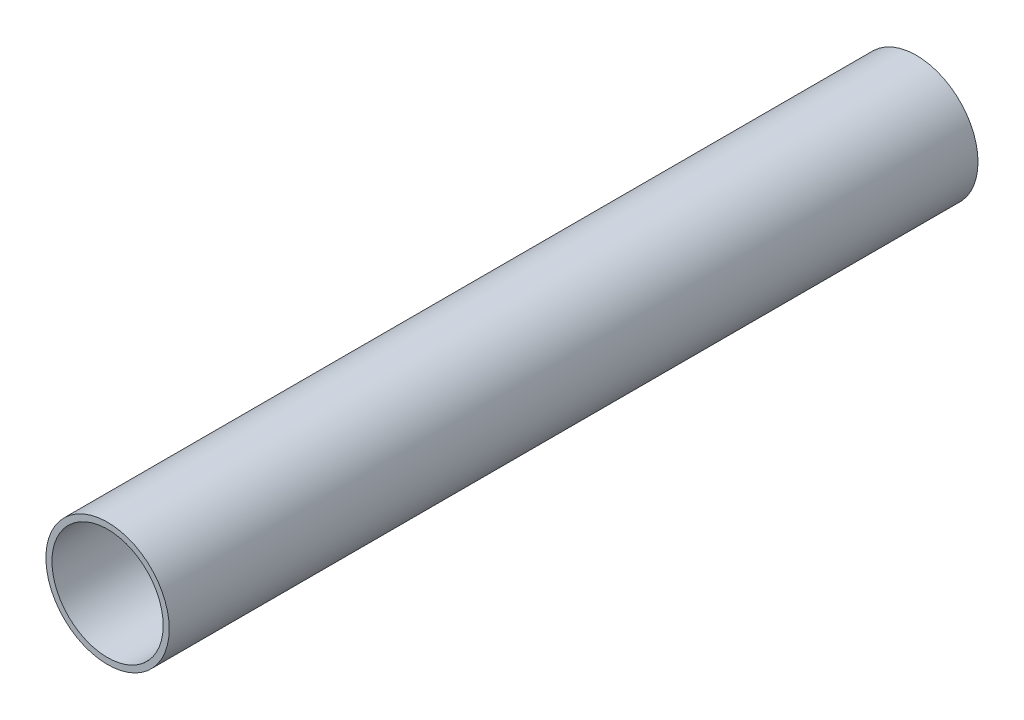
from build123d import *

# Parameters (mm, degrees)
SKETCH1_R           = 7.747
SKETCH1_R_2         = 6.985
BOSS_EXTRUDE1_DEPTH = 101.6


with BuildPart() as part:
    # Sketch1 → Boss-Extrude1 (new body)
    with BuildSketch(Plane.XY):
        Circle(SKETCH1_R)
        Circle(SKETCH1_R_2, mode=Mode.SUBTRACT)
    extrude(amount=BOSS_EXTRUDE1_DEPTH)


solid = part.part
